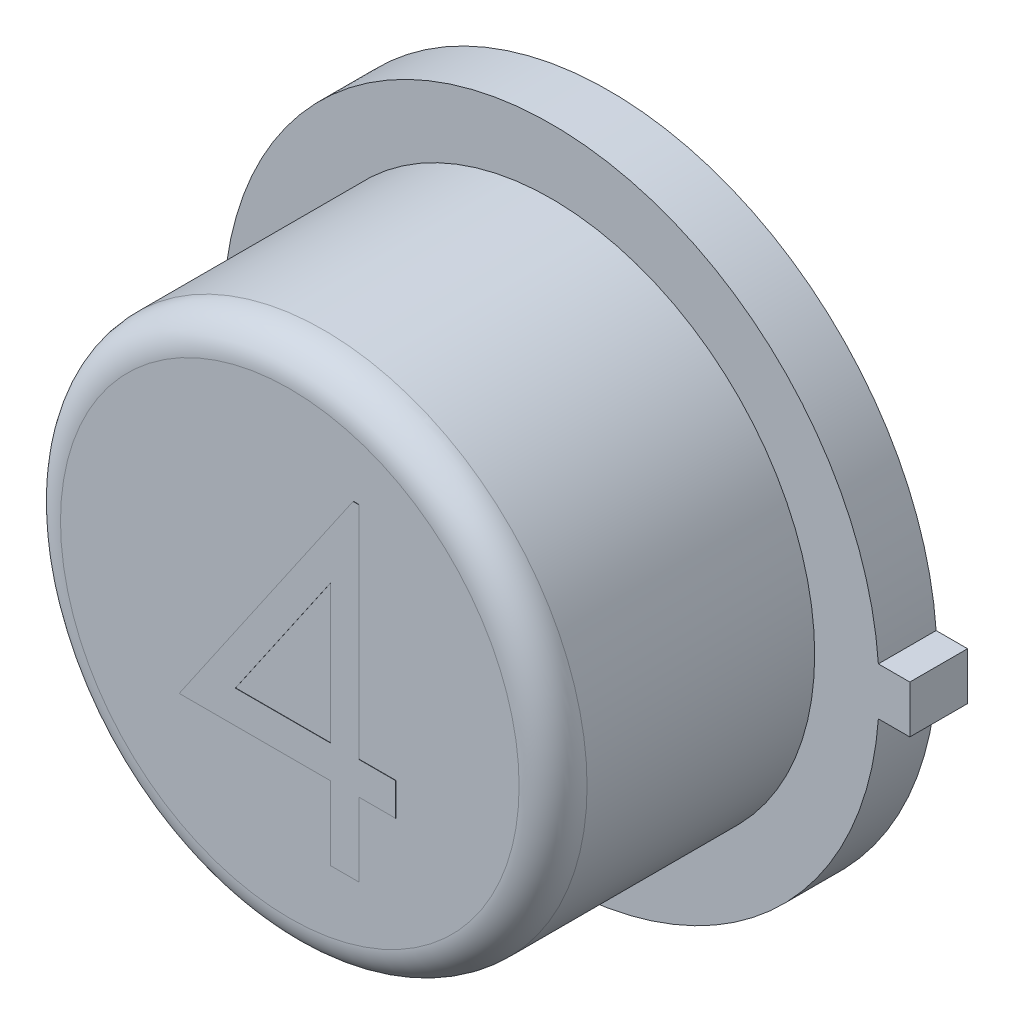
from build123d import *

# Parameters (mm, degrees)
BOSS_EXTRUDE1_DEPTH = 0.4318
SKETCH2_R           = 1.9685
BOSS_EXTRUDE2_DEPTH = 1.9558
SKETCH3_R           = 1.757566481
BOSS_EXTRUDE3_DEPTH = 0.00254
FILLET1_R           = 0.254
BOSS_EXTRUDE6_DEPTH = 0.00254


with BuildPart() as part:
    # Sketch1 → Boss-Extrude1 (new body)
    with BuildSketch(Plane.XY):
        with BuildLine():
            Line((2.6797, 0.1778), (2.4511, 0.1778))
            Line((2.4511, 0.1778), (2.44464279, 0.1778))
            ThreePointArc((2.44464279, 0.1778), (-2.4511, 0), (2.44464279, -0.1778))
            Line((2.44464279, -0.1778), (2.4511, -0.1778))
            Line((2.4511, -0.1778), (2.6797, -0.1778))
            Line((2.6797, -0.1778), (2.6797, 0.1778))
        make_face()
    extrude(amount=BOSS_EXTRUDE1_DEPTH)

    # Sketch2 → Boss-Extrude2 (add)
    with BuildSketch(Plane.XY.offset(0.4318)):
        Circle(SKETCH2_R)
    extrude(amount=BOSS_EXTRUDE2_DEPTH)

    # Sketch3 → Boss-Extrude3 (add)
    with BuildSketch(Plane(origin=(0, 0, 0), x_dir=(-1, 0, 0), z_dir=(0, 0, -1))):
        Circle(SKETCH3_R)
    extrude(amount=BOSS_EXTRUDE3_DEPTH)

    # Fillet1
    fillet1_edges = [part.edges().sort_by_distance(p)[0] for p in [
        (-1.9685, 0, 2.3876),
    ]]
    fillet(fillet1_edges, radius=FILLET1_R)

    # Sketch4 → Boss-Extrude6 (add)
    with BuildSketch(Plane.XY.offset(2.3876)):
        Polygon((0.475582181, 1.224166485), (0.518990385, 1.224166485), (0.518990385, -0.424391207), (0.79375, -0.424391207), (0.79375, -0.668621976), (0.518990385, -0.668621976), (0.518990385, -1.218141207), (0.305288462, -1.218141207), (0.305288462, -0.668621976), (-0.824278846, -0.668621976), align=None)
        Polygon((0.305288462, -0.424391207), (0.305288462, 0.609773457), (-0.404507212, -0.424391207), align=None, mode=Mode.SUBTRACT)
    extrude(amount=BOSS_EXTRUDE6_DEPTH)


solid = part.part
